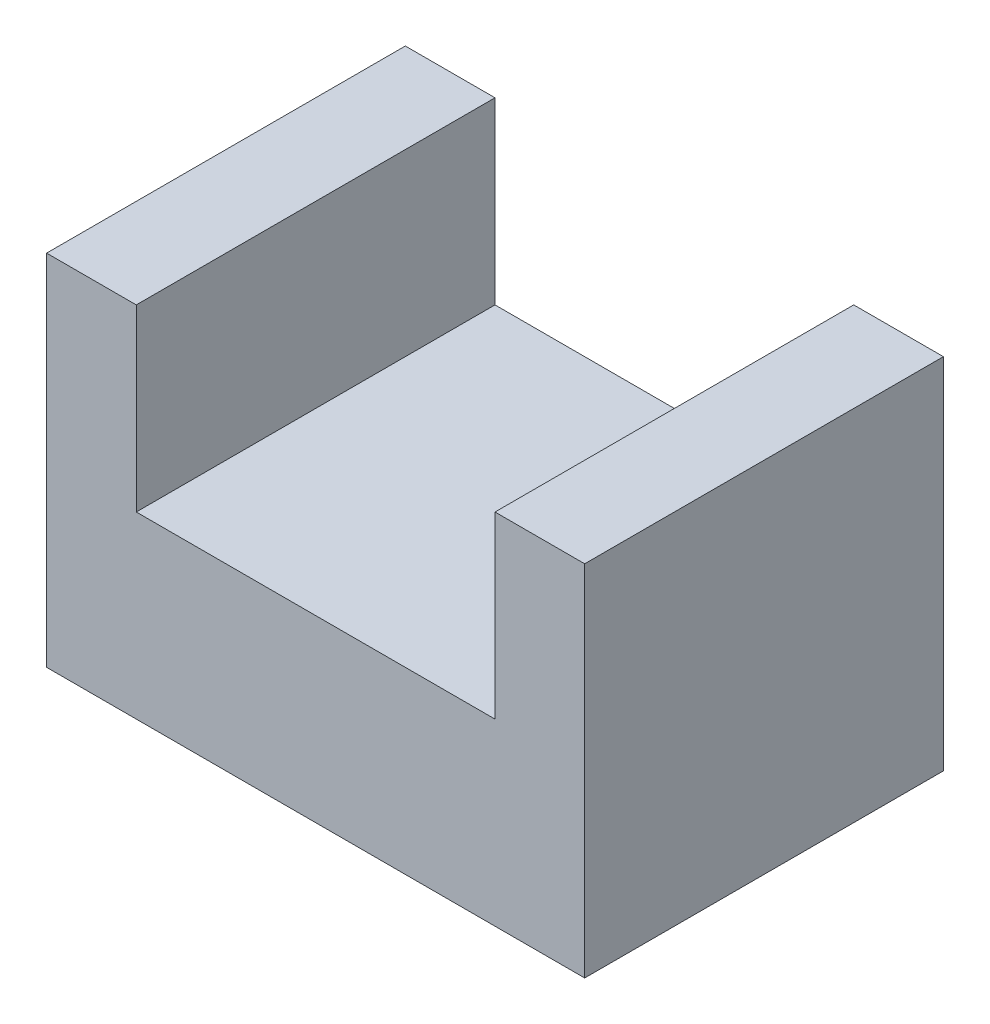
from build123d import *

# Parameters (mm, degrees)
BOSS_EXTRUDE1_DEPTH = 50.8


with BuildPart() as part:
    # Sketch2 → Boss-Extrude1 (new body)
    with BuildSketch(Plane.XY):
        Polygon((-36.615076923, 37.044923077), (-36.615076923, -13.755076923), (39.584923077, -13.755076923), (39.584923077, 37.044923077), (26.884923077, 37.044923077), (26.884923077, 11.644923077), (-23.915076923, 11.644923077), (-23.915076923, 37.044923077), align=None)
    extrude(amount=BOSS_EXTRUDE1_DEPTH)


solid = part.part
